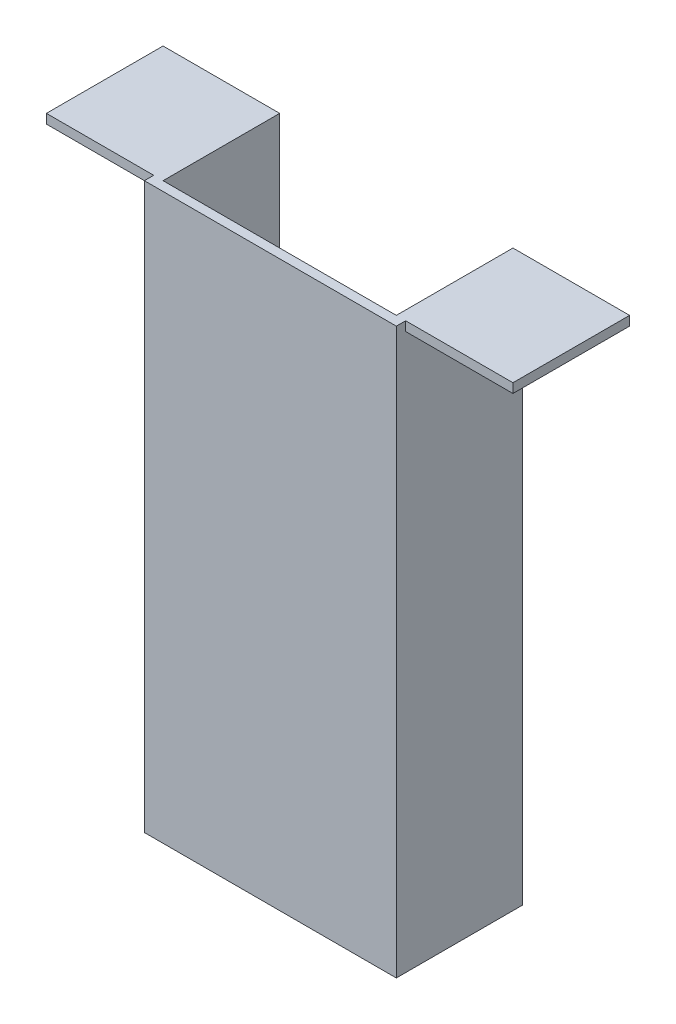
from build123d import *

# Parameters (mm, degrees)
BOSS_EXTRUDE1_DEPTH = 25
SKETCH3_W           = 54
SKETCH3_H           = 121
BOSS_EXTRUDE2_DEPTH = 2


with BuildPart() as part:
    # Sketch1 → Boss-Extrude1 (new body)
    with BuildSketch(Plane.XY):
        Polygon((2.337959557, 2.176185102), (2.337959557, 121.176185102), (-22.662040443, 121.176185102), (-22.662040443, 119.176185102), (0.337959557, 119.176185102), (0.337959557, 0.176185102), (54.337959557, 0.176185102), (54.337959557, 119.176185102), (77.337959557, 119.176185102), (77.337959557, 121.176185102), (52.337959557, 121.176185102), (52.337959557, 2.176185102), align=None)
    extrude(amount=BOSS_EXTRUDE1_DEPTH)

    # Sketch3 → Boss-Extrude2 (add)
    with BuildSketch(Plane.XY.offset(25)):
        with Locations((27.337959557, 60.676185102)):
            Rectangle(SKETCH3_W, SKETCH3_H)
    extrude(amount=BOSS_EXTRUDE2_DEPTH)


solid = part.part
